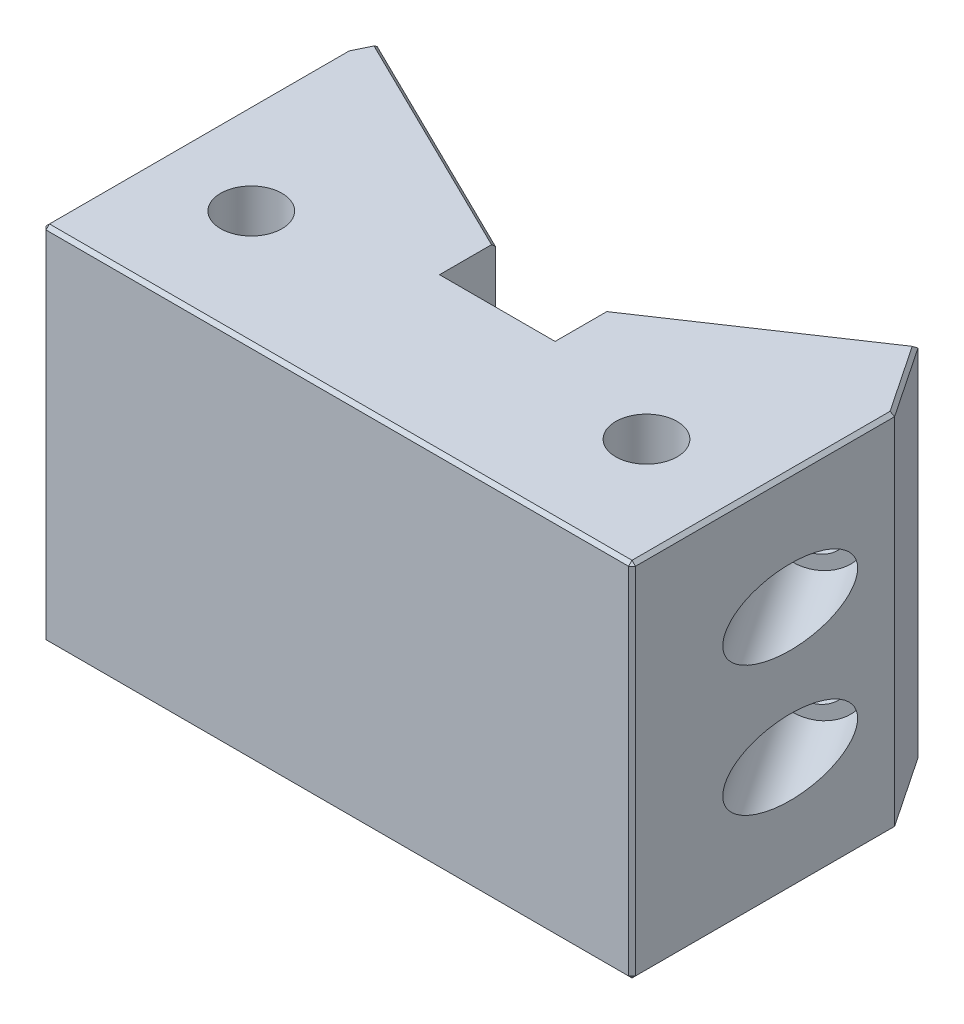
from build123d import *

# Parameters (mm, degrees)
EXTRUDE1_DEPTH                                   = 79.502
CBORE_FOR_3_8_SOCKET_HEAD_CAP_SCREW1_D           = 10.31748
CBORE_FOR_3_8_SOCKET_HEAD_CAP_SCREW1_CBORE_D     = 16.51
CBORE_FOR_3_8_SOCKET_HEAD_CAP_SCREW1_CBORE_DEPTH = 50.165
CBORE_FOR_3_8_SOCKET_HEAD_CAP_SCREW2_D           = 10.31748
CBORE_FOR_3_8_SOCKET_HEAD_CAP_SCREW2_CBORE_D     = 16.51
CBORE_FOR_3_8_SOCKET_HEAD_CAP_SCREW2_CBORE_DEPTH = 50.165
SKETCH14_W                                       = 25.4
SKETCH14_H                                       = 12.279702398
EXTRUDE2_DEPTH                                   = 80.502
CBORE_FOR_1_2_SOCKET_HEAD_CAP_SCREW1_D           = 13.49248
CBORE_FOR_1_2_SOCKET_HEAD_CAP_SCREW1_CBORE_D     = 20.6375
CBORE_FOR_1_2_SOCKET_HEAD_CAP_SCREW1_CBORE_DEPTH = 68.58
EXTRUDE3_DEPTH                                   = 80.502
CHAMFER1_SIZE                                    = 0.762


with BuildPart() as part:
    # Sketch1 → Extrude1 (new body)
    with BuildSketch(Plane(origin=(0, 0, 0), x_dir=(1, 0, 0), z_dir=(0, 1, 0))):
        Polygon((-64.77, 36.195), (-64.77, -36.195), (64.77, -36.195), (64.77, 44.162668668), (3.17795769, 2.843029897), align=None)
    extrude(amount=EXTRUDE1_DEPTH)

    # CBORE for 3/8 Socket Head Cap Screw1 (through all)
    with Locations(Plane(origin=(-27.357474291, 0, 55.735373351), x_dir=(-0.897690082, 0, -0.440627412), z_dir=(-0.440627412, 0, 0.897690082))):
        with Locations((58.851895807, -48.26), (58.851895807, -22.86)):
            CounterBoreHole(CBORE_FOR_3_8_SOCKET_HEAD_CAP_SCREW1_D / 2, CBORE_FOR_3_8_SOCKET_HEAD_CAP_SCREW1_CBORE_D / 2, CBORE_FOR_3_8_SOCKET_HEAD_CAP_SCREW1_CBORE_DEPTH)

    # CBORE for 3/8 Socket Head Cap Screw2 (through all)
    with Locations(Plane(origin=(36.462488364, 0, 54.351857685), x_dir=(-0.830439574, 0, 0.55710871), z_dir=(0.55710871, 0, 0.830439574))):
        with Locations((-52.990978547, -25.4), (-52.990978547, -53.975)):
            CounterBoreHole(CBORE_FOR_3_8_SOCKET_HEAD_CAP_SCREW2_D / 2, CBORE_FOR_3_8_SOCKET_HEAD_CAP_SCREW2_CBORE_D / 2, CBORE_FOR_3_8_SOCKET_HEAD_CAP_SCREW2_CBORE_DEPTH)

    # Sketch14 → Extrude2 (cut, through all)
    with BuildSketch(Plane(origin=(0, 79.502, 0), x_dir=(1, 0, 0), z_dir=(0, 1, 0))):
        with Locations((1.21000637, 3.902881096)):
            Rectangle(SKETCH14_W, SKETCH14_H)
    extrude(amount=-EXTRUDE2_DEPTH, mode=Mode.SUBTRACT)

    # CBORE for 1/2 Socket Head Cap Screw1 (through all)
    with Locations(Plane.XZ):
        with Locations((-44.2976, 10.795), (42.545, 10.795)):
            CounterBoreHole(CBORE_FOR_1_2_SOCKET_HEAD_CAP_SCREW1_D / 2, CBORE_FOR_1_2_SOCKET_HEAD_CAP_SCREW1_CBORE_D / 2, CBORE_FOR_1_2_SOCKET_HEAD_CAP_SCREW1_CBORE_DEPTH)

    # Sketch17 → Extrude3 (cut, through all)
    with BuildSketch(Plane.XZ):
        Polygon((-64.77, -30.609192285), (-62.560551309, -35.110501375), (-64.77, -36.195), align=None)
        Polygon((64.77, -44.162668668), (54.288806225, -37.131254796), (64.77, -21.507736545), align=None)
    extrude(amount=-EXTRUDE3_DEPTH, mode=Mode.SUBTRACT)

    # Chamfer1
    chamfer1_edges = [part.edges().sort_by_distance(p)[0] for p in [
        (0, 79.502, 36.195),
        (59.529403112, 79.502, -29.319495671),
        (59.529403112, 0, -29.319495671),
        (64.77, 79.502, 7.343631727),
        (-37.025272469, 0, -22.576616835),
        (-37.025272469, 79.502, -22.576616835),
        (64.77, 0, 7.343631727),
        (0, 0, 36.195),
        (-64.77, 0, 2.792903858),
        (-64.77, 79.502, 2.792903858),
        (-63.665275654, 79.502, -32.85984683),
        (64.77, 39.751, 36.195),
        (-63.665275654, 0, -32.85984683),
        (-64.77, 39.751, 36.195),
        (34.099406297, 0, -23.586993546),
        (34.099406297, 79.502, -23.586993546),
    ]]
    chamfer(chamfer1_edges, length=CHAMFER1_SIZE)


solid = part.part
